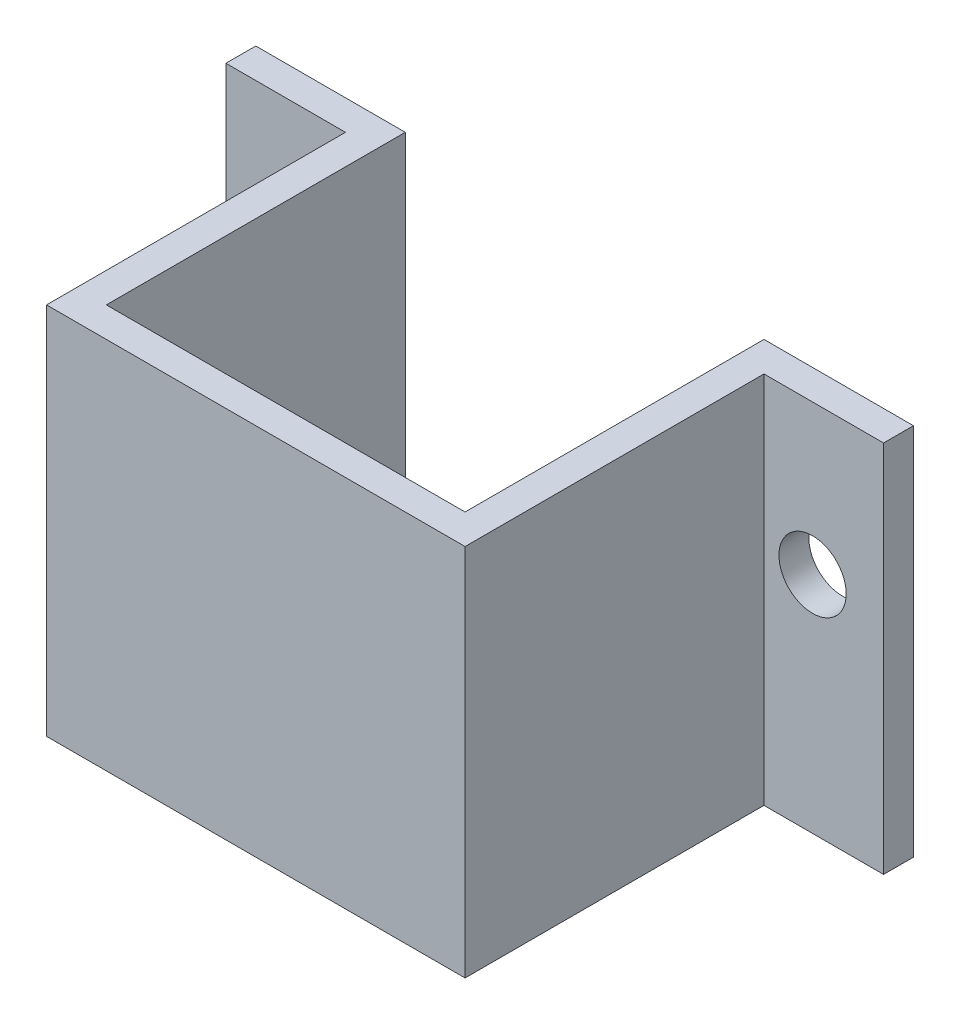
from build123d import *

# Parameters (mm, degrees)
SKETCH2_W           = 14
SKETCH2_H           = 12.5
BOSS_EXTRUDE1_DEPTH = 11
SKETCH3_W           = 12
SKETCH3_H           = 10
CUT_EXTRUDE1_DEPTH  = 12.5
SKETCH4_W           = 1
SKETCH4_H           = 12.5
BOSS_EXTRUDE2_DEPTH = 4
SKETCH5_W           = 1
SKETCH5_H           = 12.5
BOSS_EXTRUDE3_DEPTH = 4
SKETCH6_R           = 1.125
CUT_EXTRUDE2_DEPTH  = 1


with BuildPart() as part:
    # Sketch2 → Boss-Extrude1 (new body)
    with BuildSketch(Plane.XY):
        with Locations((-3.028513908, 0.880933534)):
            Rectangle(SKETCH2_W, SKETCH2_H)
    extrude(amount=BOSS_EXTRUDE1_DEPTH)

    # Sketch3 → Cut-Extrude1 (cut)
    with BuildSketch(Plane(origin=(0, -5.369066466, 0), x_dir=(-1, 0, 0), z_dir=(0, -1, 0))):
        with Locations((3.028513908, -5)):
            Rectangle(SKETCH3_W, SKETCH3_H)
    extrude(amount=-CUT_EXTRUDE1_DEPTH, mode=Mode.SUBTRACT)

    # Sketch4 → Boss-Extrude2 (add)
    with BuildSketch(Plane(origin=(3.971486092, 0, 0), x_dir=(0, 0, -1), z_dir=(1, 0, 0))):
        with Locations((-0.5, 0.880933534)):
            Rectangle(SKETCH4_W, SKETCH4_H)
    extrude(amount=BOSS_EXTRUDE2_DEPTH)

    # Sketch5 → Boss-Extrude3 (add)
    with BuildSketch(Plane.ZY.offset(10.028513908)):
        with Locations((0.5, 0.880933534)):
            Rectangle(SKETCH5_W, SKETCH5_H)
    extrude(amount=BOSS_EXTRUDE3_DEPTH)

    # Sketch6 → Cut-Extrude2 (cut)
    with BuildSketch(Plane.XY.offset(1)):
        with Locations((-11.653513908, 2.130933534)):
            Circle(SKETCH6_R)
        with Locations((5.596486092, 2.130933534)):
            Circle(SKETCH6_R)
    extrude(amount=-CUT_EXTRUDE2_DEPTH, mode=Mode.SUBTRACT)


solid = part.part
